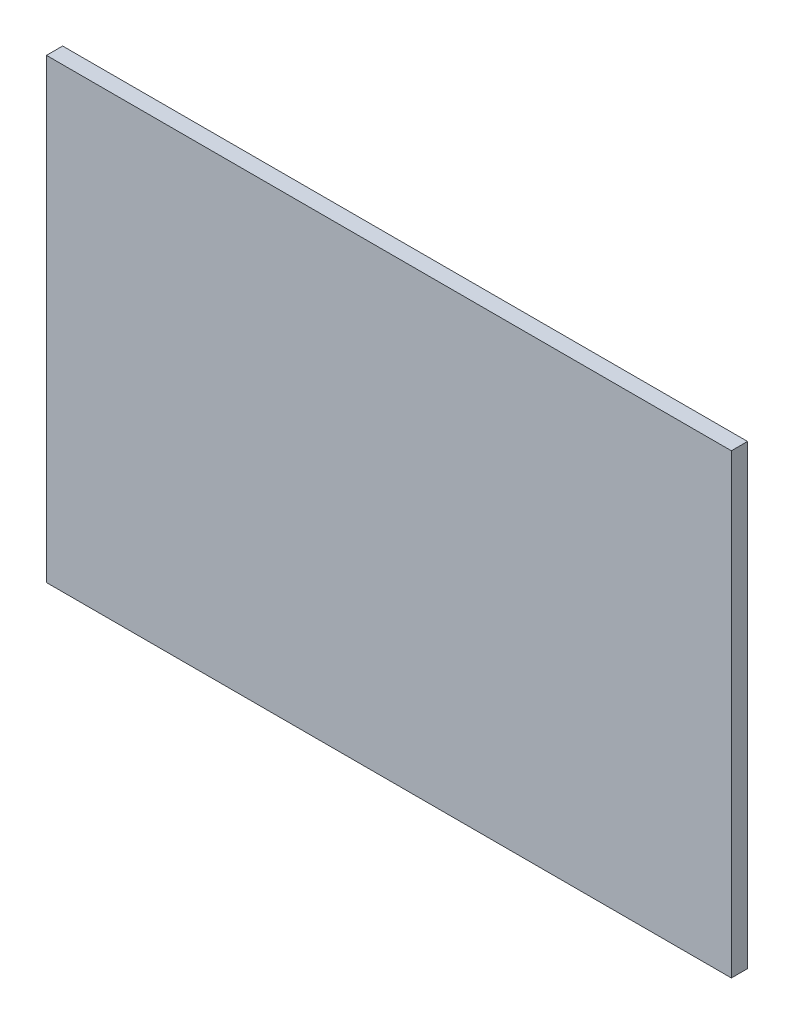
from build123d import *

# Parameters (mm, degrees)
SKETCH1_W           = 80.52
SKETCH1_H           = 53.68
BOSS_EXTRUDE1_DEPTH = 1.9


with BuildPart() as part:
    # Sketch1 → Boss-Extrude1 (new body)
    with BuildSketch(Plane.XY):
        Rectangle(SKETCH1_W, SKETCH1_H)
    extrude(amount=BOSS_EXTRUDE1_DEPTH)


solid = part.part
